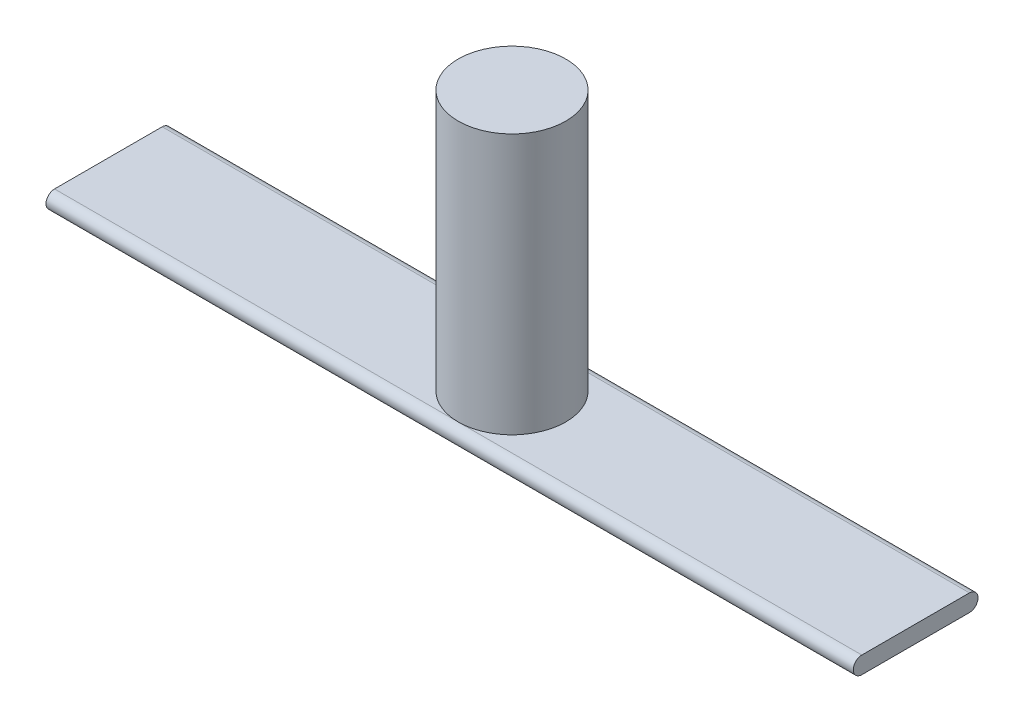
from build123d import *

# Parameters (mm, degrees)
SKETCH3_R           = 1
BOSS_EXTRUDE1_DEPTH = 5
BOSS_EXTRUDE2_DEPTH = 7.5


with BuildPart() as part:
    # Sketch3 → Boss-Extrude1 (new body)
    with BuildSketch(Plane(origin=(0, 0, 0), x_dir=(1, 0, 0), z_dir=(0, 1, 0))):
        Circle(SKETCH3_R)
    extrude(amount=BOSS_EXTRUDE1_DEPTH)

    # Sketch4 → Boss-Extrude2 (add, symmetric)
    with BuildSketch(Plane(origin=(0, 0, 0), x_dir=(0, 0, -1), z_dir=(1, 0, 0))):
        with BuildLine():
            Line((-1, 0.158659908), (1, 0.158659908))
            ThreePointArc((1, 0.158659908), (1.158659908, 0), (1, -0.158659908))
            Line((1, -0.158659908), (-1, -0.158659908))
            ThreePointArc((-1, -0.158659908), (-1.158659908, 0), (-1, 0.158659908))
        make_face()
    extrude(amount=BOSS_EXTRUDE2_DEPTH, both=True)


solid = part.part
